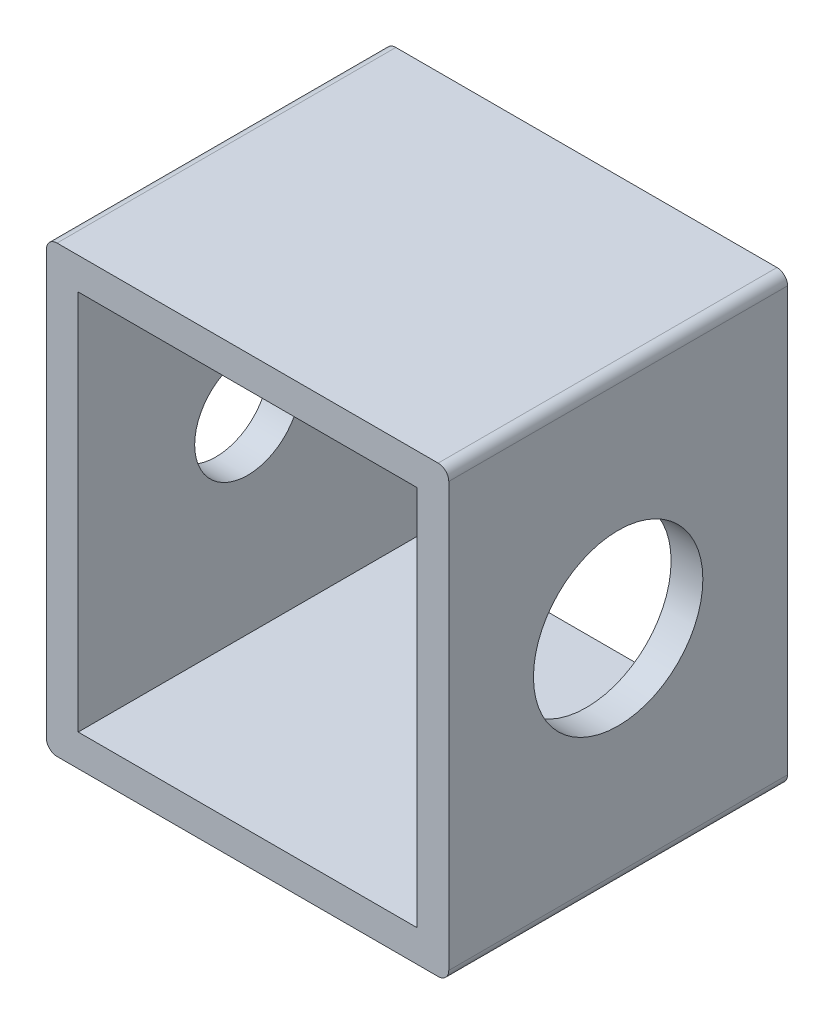
from build123d import *

# Parameters (mm, degrees)
DODANIE_WYCI_GNI_CIE1_DEPTH = 16
SKORUPA1_T                  = -1.5
WYTNIJ_WYCI_GNI_CIE2_REACH  = 21
SZKIC12_R                   = 2.5
WYTNIJ_WYCI_GNI_CIE3_REACH  = 21
SZKIC13_R                   = 4


with BuildPart() as part:
    # Szkic1 → Dodanie-wyciągnięcie1 (new body)
    with BuildSketch(Plane.XY):
        with BuildLine():
            Line((0.5, 0), (18.5, 0))
            ThreePointArc((18.5, 0), (18.853553391, 0.146446609), (19, 0.5))
            Line((19, 0.5), (19, 20.5))
            ThreePointArc((19, 20.5), (18.853553391, 20.853553391), (18.5, 21))
            Line((18.5, 21), (0.5, 21))
            ThreePointArc((0.5, 21), (0.146446609, 20.853553391), (0, 20.5))
            Line((0, 20.5), (0, 0.5))
            ThreePointArc((0, 0.5), (0.146446609, 0.146446609), (0.5, 0))
        make_face()
    extrude(amount=DODANIE_WYCI_GNI_CIE1_DEPTH)

    # Skorupa1
    skorupa1_openings = [part.faces().sort_by_distance(p)[0] for p in [
        (9.5, 10.5, 16),
        (9.5, 10.5, 0),
    ]]
    offset(amount=SKORUPA1_T, openings=skorupa1_openings, kind=Kind.INTERSECTION)

    # Szkic12 → Wytnij-wyciągnięcie2 (cut, up to next)
    with BuildSketch(Plane.ZY, mode=Mode.PRIVATE) as wytnij_wyci_gni_cie2_sk1:
        with Locations((8, 10.5)):
            Circle(SZKIC12_R)
    wytnij_wyci_gni_cie2_tool1 = extrude(wytnij_wyci_gni_cie2_sk1.sketch, amount=-WYTNIJ_WYCI_GNI_CIE2_REACH, mode=Mode.PRIVATE) & part.part
    add(wytnij_wyci_gni_cie2_tool1.solids().sort_by_distance((0, 10.5, 8))[0], mode=Mode.SUBTRACT)

    # Szkic13 → Wytnij-wyciągnięcie3 (cut, up to next)
    with BuildSketch(Plane(origin=(19, 0, 0), x_dir=(0, 0, -1), z_dir=(1, 0, 0)), mode=Mode.PRIVATE) as wytnij_wyci_gni_cie3_sk1:
        with Locations((-8, 10.5)):
            Circle(SZKIC13_R)
    wytnij_wyci_gni_cie3_tool1 = extrude(wytnij_wyci_gni_cie3_sk1.sketch, amount=-WYTNIJ_WYCI_GNI_CIE3_REACH, mode=Mode.PRIVATE) & part.part
    add(wytnij_wyci_gni_cie3_tool1.solids().sort_by_distance((19, 10.5, 8))[0], mode=Mode.SUBTRACT)


solid = part.part
